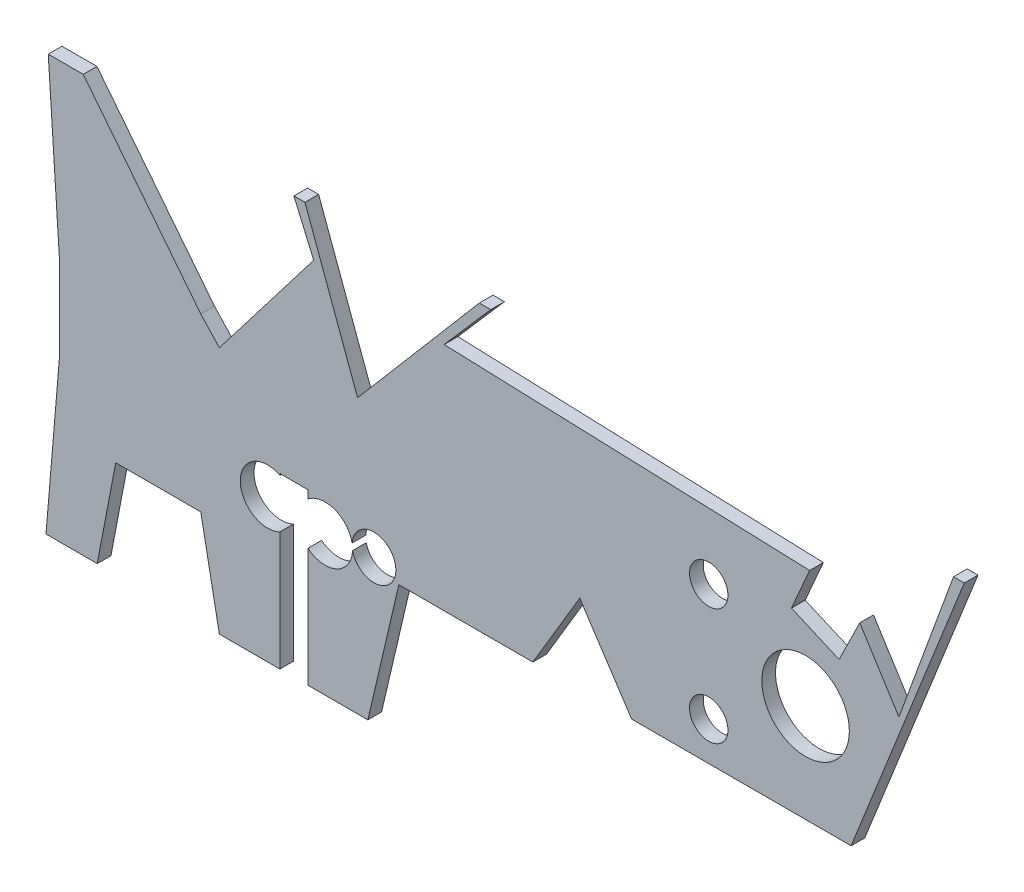
from build123d import *

# Parameters (mm, degrees)
SKETCH_1_W          = 174.091607372
SKETCH_1_H          = 60.823122747
EXTRUDE_1_DEPTH     = 2
SKETCH_2_R          = 6.75
SKETCH_2_R_2        = 4
SKETCH_2_R_3        = 6.387609309
CUT_EXTRUDE_2_DEPTH = 3
SKETCH_5_R          = 2.8
SKETCH_5_R_2        = 3.2
CUT_EXTRUDE_6_DEPTH = 3


with BuildPart() as part:
    # Эскиз1 → Бобышка-Вытянуть1 (new body)
    with BuildSketch(Plane.XY):
        with Locations((41.416369032, 15.037436288)):
            Rectangle(SKETCH_1_W, SKETCH_1_H)
    extrude(amount=EXTRUDE_1_DEPTH)

    # Эскиз2 → Вырез-Вытянуть2 (cut, through all)
    with BuildSketch(Plane.XY.offset(2)):
        with Locations((-19.785334363, 17.425924278)):
            Circle(SKETCH_2_R)
        with Locations((26.791510955, 5.539037957)):
            Circle(SKETCH_2_R_2)
        with Locations((35.178515275, 5.052050609)):
            Circle(SKETCH_2_R_2)
        with Locations((105.297300125, 18.321325083)):
            Circle(SKETCH_2_R_3)
    extrude(amount=-CUT_EXTRUDE_2_DEPTH, mode=Mode.SUBTRACT)

    # Эскиз5 → Вырез-Вытянуть6 (cut, through all)
    with BuildSketch(Plane.XY.offset(2)):
        with Locations((91.162128274, 26.645923824)):
            Circle(SKETCH_5_R)
        with Locations((91.162128274, 9.6)):
            Circle(SKETCH_5_R)
        with Locations((42.296935023, 5.602595819)):
            Circle(SKETCH_5_R_2)
        Polygon((28.570706192, 9.34764981), (28.570706192, -16.12332621), (32.666265218, -16.12332621), (32.666265218, 9.330532976), align=None)
        Polygon((33.503712587, 38.765606149), (19.738187242, 20.818838125), (17.024936958, 23.734062815), (-4.96394501, 51.572688279), (27.970840429, 51.572688279), align=None)
        Polygon((31.662167761, 46.983470514), (39.910203219, 24.587362026), (58.988646835, 46.983470514), align=None)
        Polygon((4.611696012, -1.281488831), (17.024936958, -1.281488831), (19.738187242, -15.374125086), (1.915533217, -15.374125086), align=None)
        Polygon((-5.563318521, -15.374125086), (-3.57038705, 8.280770389), (-3.57038705, 19.874672628), (-5.563318521, 50.475189584), (-48.013678964, 50.475189584), (-48.013678964, -15.374125086), align=None)
        Polygon((72.33728383, 15.460155755), (65.492559947, 3.970797808), (45.936205994, 3.970797808), (41.416369032, -15.374125086), (128.462172718, -15.374125086), (128.462172718, 45.448997661), (111.938900584, 3.970797808), (79.915370987, 3.970797808), align=None)
        Polygon((61.092380308, 47.449740359), (52.544642812, 37.635973837), (105.888722073, 35.749872981), (103.242302386, 29.670868316), (110.190804078, 26.645923824), (113.207690043, 32.789853089), (118.919189497, 23.734062815), (126.889373288, 45.448997661), align=None)
    extrude(amount=-CUT_EXTRUDE_6_DEPTH, mode=Mode.SUBTRACT)


solid = part.part
